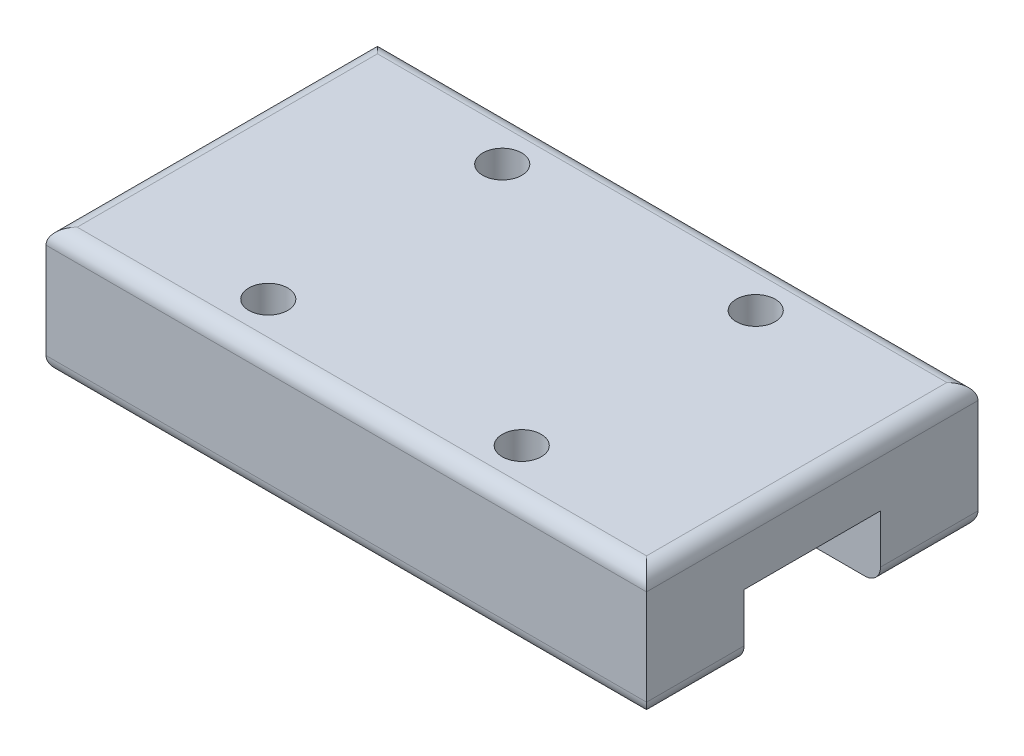
from build123d import *

# Parameters (mm, degrees)
SKETCH_1_W          = 30.8
SKETCH_1_H          = 6.5
EXTRUDE_1_DEPTH     = 8.5
SKETCH_2_R          = 1
CUT_EXTRUDE_1_DEPTH = 2.5
CUT_EXTRUDE_2_REACH = 32.8
SKETCH_3_W          = 7
SKETCH_3_H          = 3.3
FILLET_1_R          = 0.8


with BuildPart() as part:
    # 草图1 → 凸台-拉伸1 (new body, symmetric)
    with BuildSketch(Plane.XY):
        Rectangle(SKETCH_1_W, SKETCH_1_H)
    extrude(amount=EXTRUDE_1_DEPTH, both=True)

    # 草图2 → 切除-拉伸1 (cut)
    with BuildSketch(Plane(origin=(0, 3.25, 0), x_dir=(1, 0, 0), z_dir=(0, 1, 0))):
        with Locations((-6.5, 6)):
            Circle(SKETCH_2_R)
        with Locations((-6.5, -6)):
            Circle(SKETCH_2_R)
        with Locations((6.5, 6)):
            Circle(SKETCH_2_R)
        with Locations((6.5, -6)):
            Circle(SKETCH_2_R)
    extrude(amount=-CUT_EXTRUDE_1_DEPTH, mode=Mode.SUBTRACT)

    # 草图3 → 切除-拉伸2 (cut, up to next)
    with BuildSketch(Plane.ZY.offset(15.4), mode=Mode.PRIVATE) as cut_extrude_2_sk1:
        with Locations((0, -1.6)):
            Rectangle(SKETCH_3_W, SKETCH_3_H)
    cut_extrude_2_tool1 = extrude(cut_extrude_2_sk1.sketch, amount=-CUT_EXTRUDE_2_REACH, mode=Mode.PRIVATE) & part.part
    add(cut_extrude_2_tool1.solids().sort_by_distance((-15.4, -1.6, 0))[0], mode=Mode.SUBTRACT)

    # 圆角1
    fillet_1_edges = [part.edges().sort_by_distance(p)[0] for p in [
        (0, 3.25, 8.5),
        (15.4, -3.25, -6),
        (-15.4, -3.25, -6),
        (0, 3.25, -8.5),
        (0, -3.25, -8.5),
        (0, -3.25, 8.5),
        (-15.4, 3.25, 0),
        (15.4, 3.25, 0),
        (15.4, -3.25, 6),
        (-15.4, -3.25, 6),
    ]]
    fillet(fillet_1_edges, radius=FILLET_1_R)


solid = part.part
